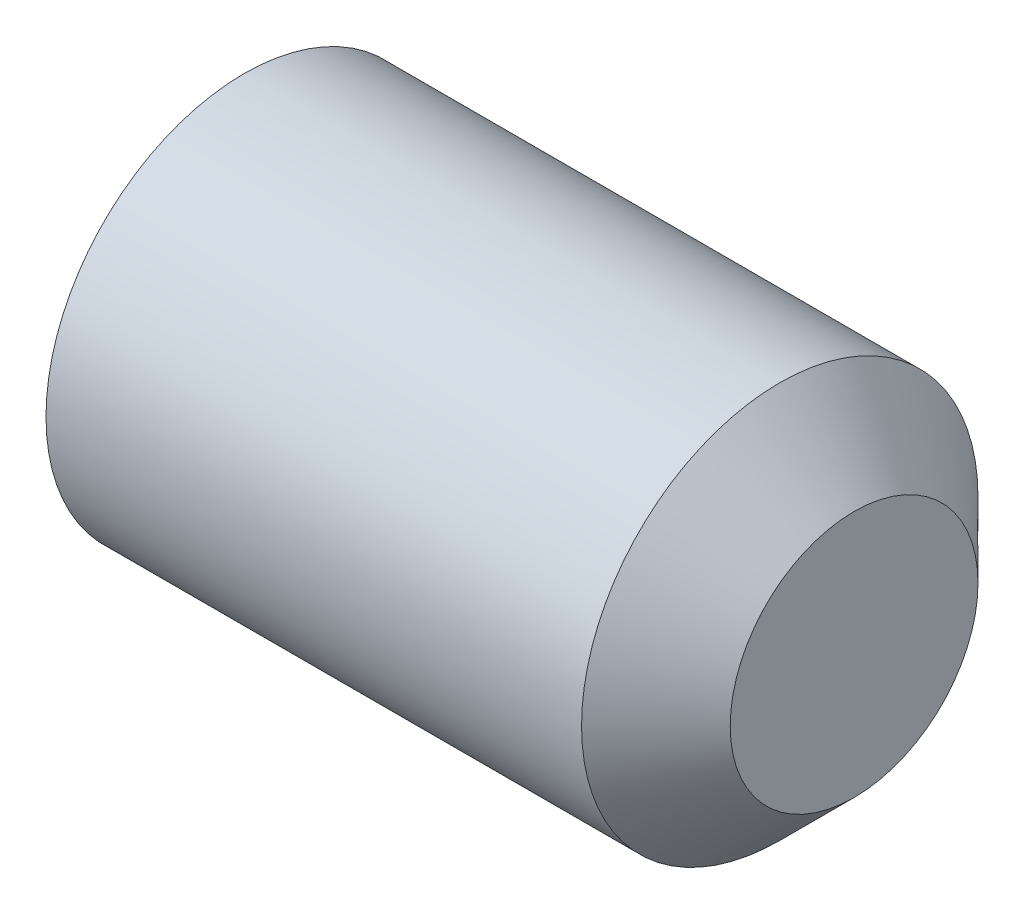
from build123d import *

# Parameters (mm, degrees)
SKETCH_1_W          = 6.5
SKETCH_1_H          = 2
CUT_EXTRUDE_1_DEPTH = 1.5
CHAMFER_1_SIZE      = 0.75
CHAMFER_2_SIZE      = 0.6
CHAMFER_2_SIZE2     = 0.346410161
FILLET_1_R          = 0.1


with BuildPart() as part:
    # Эскиз1 → Повернуть1 (revolve)
    with BuildSketch(Plane(origin=(0, 0, 0), x_dir=(-1, 0, 0), z_dir=(0, 0, -1))):
        with Locations((-3.25, 1)):
            Rectangle(SKETCH_1_W, SKETCH_1_H)
    revolve(axis=Axis((6.5, 0, 0), (-1, 0, 0)))

    # Эскиз2 → Вырез-Вытянуть1 (cut)
    with BuildSketch(Plane.ZY):
        Polygon((1.154700538, 0), (0.577350269, 1), (-0.577350269, 1), (-1.154700538, 0), (-0.577350269, -1), (0.577350269, -1), align=None)
    extrude(amount=-CUT_EXTRUDE_1_DEPTH, mode=Mode.SUBTRACT)

    # Фаска1
    chamfer_1_edges = [part.edges().sort_by_distance(p)[0] for p in [
        (6.5, -2, 0),
    ]]
    chamfer(chamfer_1_edges, length=CHAMFER_1_SIZE)

    # Фаска2
    chamfer_2_edges = [part.edges().sort_by_distance(p)[0] for p in [
        (0, -2, 0),
    ]]
    chamfer_2_side = [part.faces().sort_by_distance(p)[0] for p in [
        (0, -1.943431458, 0),
    ]]
    chamfer(chamfer_2_edges, length=CHAMFER_2_SIZE, length2=CHAMFER_2_SIZE2, reference=chamfer_2_side[0])

    # Скругление1
    fillet_1_edges = [part.edges().sort_by_distance(p)[0] for p in [
        (1.5, -0.5, 0.866025404),
        (1.5, -1, 0),
        (1.5, -0.5, -0.866025404),
        (1.5, 0.5, -0.866025404),
        (1.5, 1, 0),
        (1.5, 0.5, 0.866025404),
        (0, -0.5, 0.866025404),
        (0, 0.5, 0.866025404),
        (0, 1, 0),
        (0, 0.5, -0.866025404),
        (0, -0.5, -0.866025404),
        (0, -1, 0),
        (0, -1.4, 0),
    ]]
    fillet(fillet_1_edges, radius=FILLET_1_R)


solid = part.part
